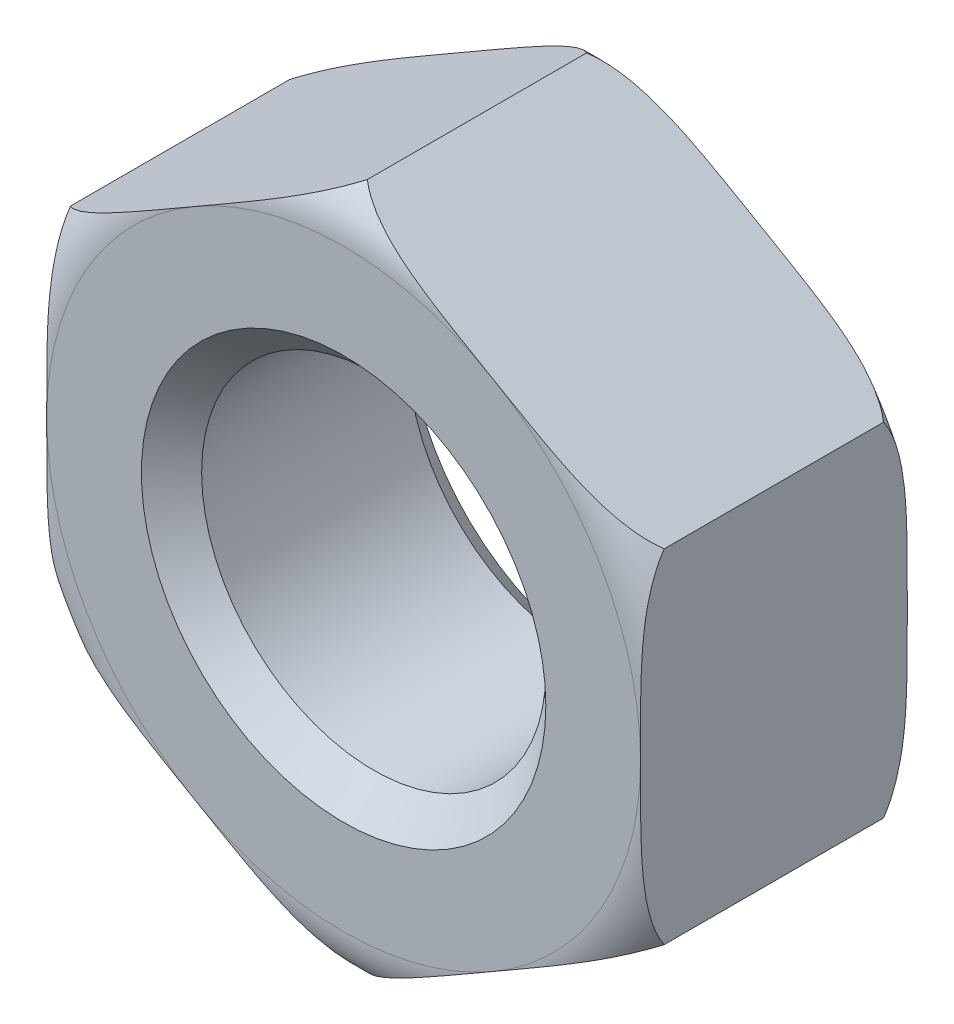
from build123d import *

# Parameters (mm, degrees)
SKETCH1_R           = 2
BOSS_EXTRUDE1_DEPTH = 3.1
CHAMFER1_SIZE       = 0.35


with BuildPart() as part:
    # Sketch1 → Boss-Extrude1 (new body)
    with BuildSketch(Plane.XY):
        Polygon((3.45, 1.991858429), (0, 3.983716857), (-3.45, 1.991858429), (-3.45, -1.991858429), (0, -3.983716857), (3.45, -1.991858429), align=None)
        Circle(SKETCH1_R, mode=Mode.SUBTRACT)
    extrude(amount=BOSS_EXTRUDE1_DEPTH)

    # Chamfer1
    chamfer1_edges = [part.edges().sort_by_distance(p)[0] for p in [
        (-2, 0, 0),
        (-2, 0, 3.1),
    ]]
    chamfer(chamfer1_edges, length=CHAMFER1_SIZE)

    # Sketch2 → Cut-Revolve1 (revolve, cut)
    with BuildSketch(Plane(origin=(0, 0, 0), x_dir=(1, 0, 0), z_dir=(0, 1, 0))):
        with BuildLine():
            Line((-4, -0.3), (-4.500819954, -0.3))
            Line((-4.500819954, -0.3), (-4.500819954, 0.361239255))
            Line((-4.500819954, 0.361239255), (-3.45, 0.361239255))
            Line((-3.45, 0.361239255), (-3.45, 0))
            ThreePointArc((-3.45, 0), (-3.763249102, -0.079876646), (-4, -0.3))
        make_face()
        with BuildLine():
            Line((-3.45, -3.461239255), (-3.45, -3.1))
            ThreePointArc((-3.45, -3.1), (-3.763249102, -3.020123354), (-4, -2.8))
            Line((-4, -2.8), (-4.500819954, -2.8))
            Line((-4.500819954, -2.8), (-4.500819954, -3.461239255))
            Line((-4.500819954, -3.461239255), (-3.45, -3.461239255))
        make_face()
    revolve(axis=Axis((0, 0, 1.55), (0, 0, -1)), mode=Mode.SUBTRACT)


solid = part.part
